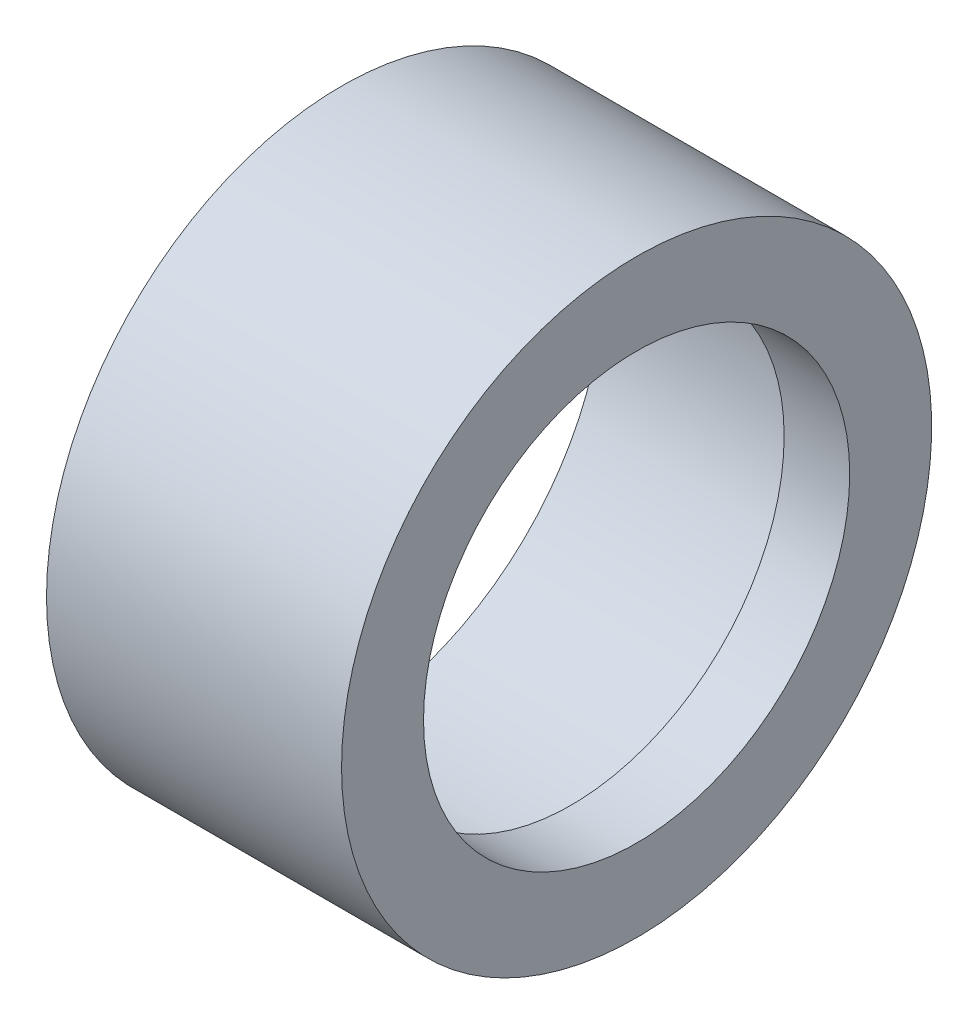
from build123d import *


with BuildPart() as part:
    # Эскиз1 → Повернуть1 (revolve)
    with BuildSketch(Plane.XY):
        Polygon((0, 4), (3.5, 4), (3.5, 3.25), (4.5, 3.25), (4.5, 4.5), (0, 4.5), align=None)
    revolve(axis=Axis((0, 0, 0), (1, 0, 0)))


solid = part.part
